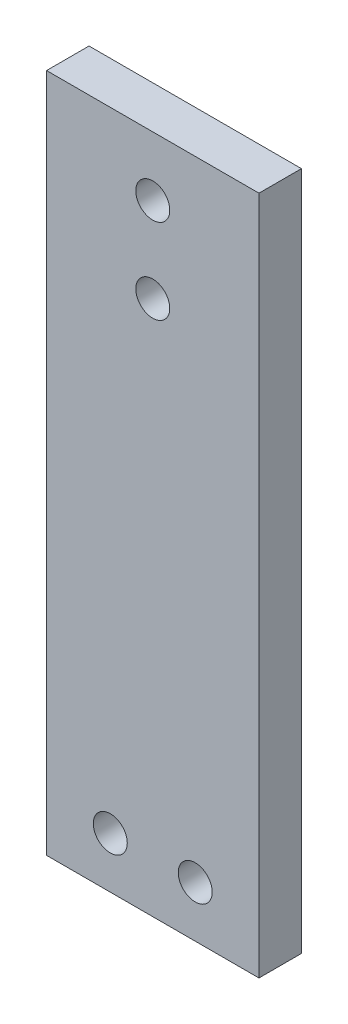
from build123d import *

# Parameters (mm, degrees)
SKETCH_1_W          = 25
SKETCH_1_H          = 80
EXTRUDE_1_DEPTH     = 5
SKETCH_2_R          = 2
CUT_EXTRUDE_1_DEPTH = 6


with BuildPart() as part:
    # 草图1 → 凸台-拉伸1 (new body)
    with BuildSketch(Plane.XY):
        Rectangle(SKETCH_1_W, SKETCH_1_H)
    extrude(amount=-EXTRUDE_1_DEPTH)

    # 草图2 → 切除-拉伸1 (cut, through all)
    with BuildSketch(Plane.XY):
        with Locations((0, 33)):
            Circle(SKETCH_2_R)
        with Locations((0, 23)):
            Circle(SKETCH_2_R)
        with Locations((-5, -34)):
            Circle(SKETCH_2_R)
        with Locations((5, -34)):
            Circle(SKETCH_2_R)
    extrude(amount=-CUT_EXTRUDE_1_DEPTH, mode=Mode.SUBTRACT)


solid = part.part
